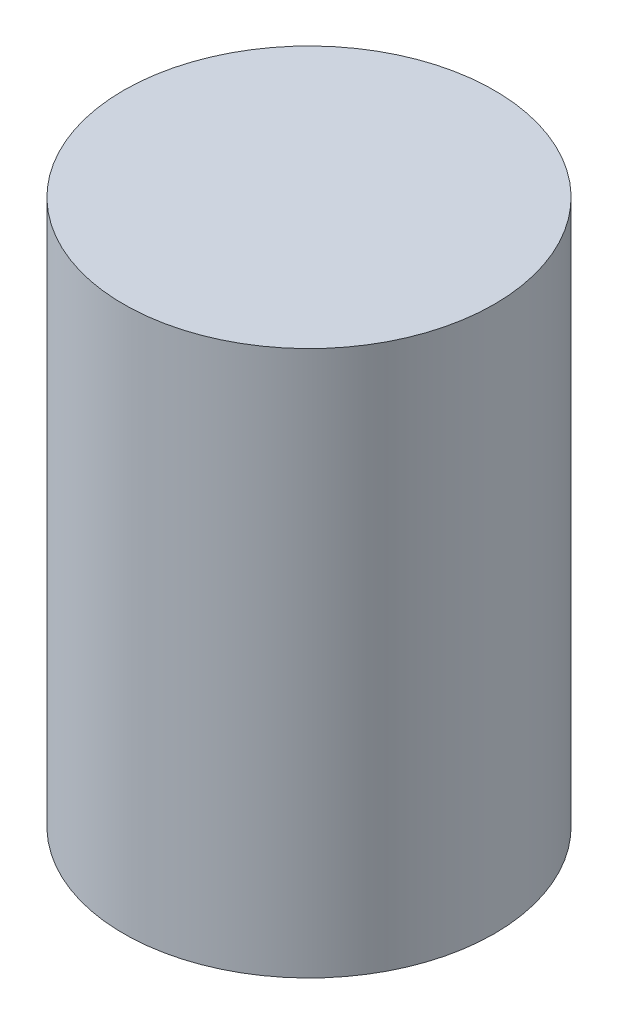
from build123d import *


with BuildPart() as part:
    # Sketch1 → Revolve1 (revolve)
    with BuildSketch(Plane.XY):
        with BuildLine():
            Line((-7.5, -10), (-17, -10))
            Line((-17, -10), (-17, 40))
            Line((-17, 40), (0, 40))
            Line((0, 40), (0, 12.5))
            ThreePointArc((0, 12.5), (-11.858541226, 3.952847075), (-7.5, -10))
        make_face()
    revolve(axis=Axis((0, 0, 0), (0, 1, 0)))


solid = part.part
